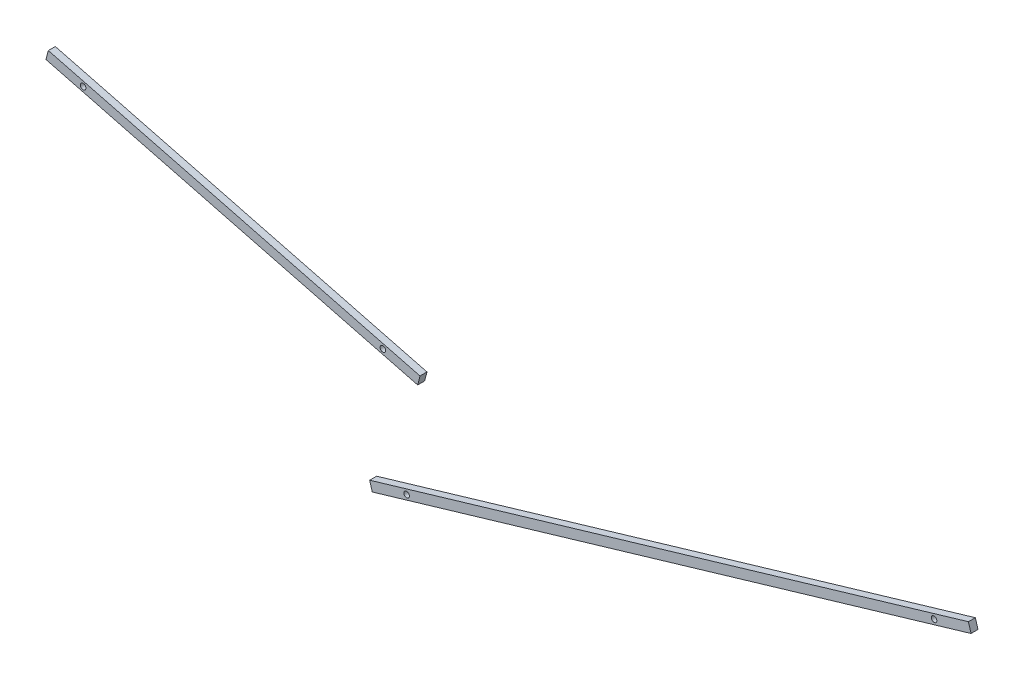
from build123d import *

# Parameters (mm, degrees)
BOSS_EXTRUDE1_DEPTH            = 4.7625
BOSS_EXTRUDE1_2_DEPTH          = 4.7625
SKETCH6_W                      = 1.89865
SKETCH6_H                      = 4.7625
F_6_CLEARANCE_HOLE1_AT_2_COUNT = 2
F_6_CLEARANCE_HOLE1_AT_2_PITCH = 377.84858633
F_6_CLEARANCE_HOLE1_AT_3_COUNT = 2
F_6_CLEARANCE_HOLE1_AT_3_PITCH = 582.170968688
F_6_CLEARANCE_HOLE1_AT_4_COUNT = 2
F_6_CLEARANCE_HOLE1_AT_4_PITCH = 375.932176835


with BuildPart() as part:
    # Sketch4 → Boss-Extrude1 (new body)
    with BuildSketch(Plane.XY):
        Polygon((420.373410583, 450.13359804), (166.308154013, 515.747181299), (164.720331493, 509.598903521), (418.785588063, 443.985320261), align=None)
    extrude(amount=BOSS_EXTRUDE1_DEPTH)


with BuildPart() as body_2:
    # Sketch4 → Boss-Extrude1 2 (new body)
    with BuildSketch(Plane.XY):
        Polygon((795.224225991, 492.084261956), (385.965820385, 371.221082339), (387.764328284, 365.131101277), (797.022733889, 485.994280894), align=None)
    extrude(amount=BOSS_EXTRUDE1_2_DEPTH)

    # Sketch6 → #6 Clearance Hole1 (revolve, cut)
    with BuildSketch(Plane(origin=(771.763555691, 481.845239831, 4.7625), x_dir=(0, -1, 0), z_dir=(1, 0, 0))):
        with Locations((0.949325, 2.38125)):
            Rectangle(SKETCH6_W, SKETCH6_H)
    f_6_clearance_hole1 = revolve(axis=Axis((771.763555691, 481.845239831, 11.1125), (0, 0, -1)), mode=Mode.SUBTRACT)

    # #6 Clearance Hole1 at 4: #6 Clearance Hole1 ×2
    with Locations(*[Vector(-0.959052136, -0.28322959, 0) * (i * F_6_CLEARANCE_HOLE1_AT_4_PITCH) for i in range(1, F_6_CLEARANCE_HOLE1_AT_4_COUNT)]):
        add(f_6_clearance_hole1, mode=Mode.SUBTRACT)


with BuildPart() as part_1:
    add(part.part)

    # #6 Clearance Hole1 at 2: #6 Clearance Hole1 ×2
    with Locations(*[Vector(-0.997164423, -0.075253664, 0) * (i * F_6_CLEARANCE_HOLE1_AT_2_PITCH) for i in range(1, F_6_CLEARANCE_HOLE1_AT_2_COUNT)]):
        add(f_6_clearance_hole1, mode=Mode.SUBTRACT)

    # #6 Clearance Hole1 at 3: #6 Clearance Hole1 ×2
    with Locations(*[Vector(-0.999115781, 0.042043513, 0) * (i * F_6_CLEARANCE_HOLE1_AT_3_PITCH) for i in range(1, F_6_CLEARANCE_HOLE1_AT_3_COUNT)]):
        add(f_6_clearance_hole1, mode=Mode.SUBTRACT)


solid = Compound([body_2.part, part_1.part])
